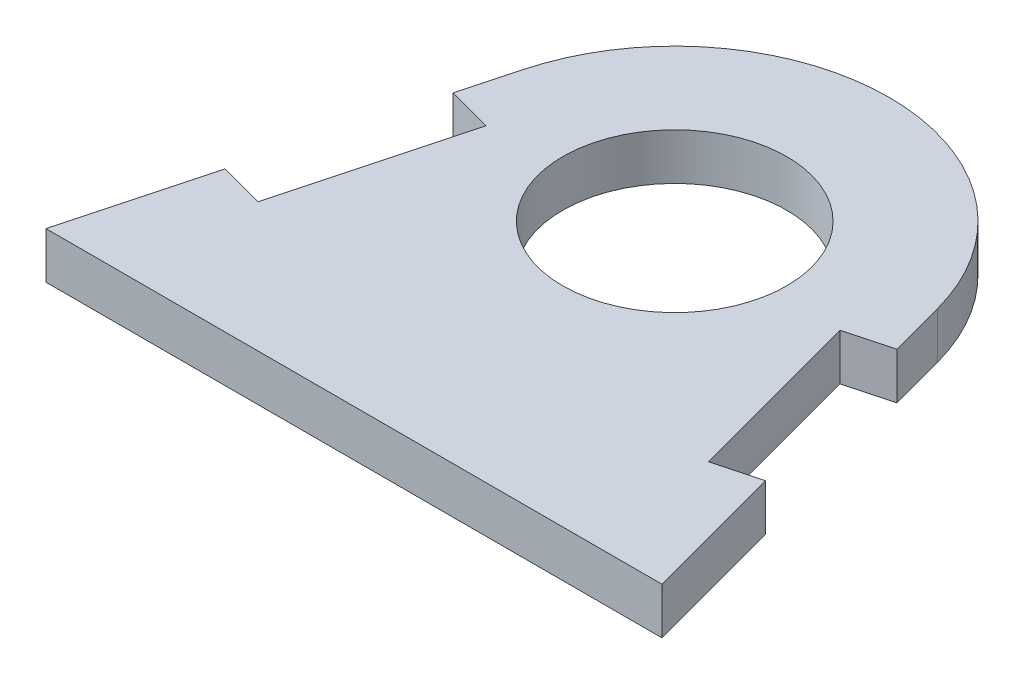
from build123d import *

# Parameters (mm, degrees)
SKETCH1_R           = 7.65
BOSS_EXTRUDE1_DEPTH = 1.5875


with BuildPart() as part:
    # Sketch1 → Boss-Extrude1 (new, symmetric)
    with BuildSketch(Plane(origin=(0, 0, 0), x_dir=(1, 0, 0), z_dir=(0, 1, 0))):
        with BuildLine():
            Line((-18.450042271, 9.659258263), (-21.038232722, 0))
            Line((-21.038232722, 0), (21.038232722, 0))
            Line((21.038232722, 0), (18.450042271, 9.659258263))
            Line((18.450042271, 9.659258263), (15.383227773, 8.837507795))
            Line((15.383227773, 8.837507795), (12.0962259, 21.104765789))
            Line((12.0962259, 21.104765789), (15.163040398, 21.926516257))
            Line((15.163040398, 21.926516257), (14.150813355, 25.704199011))
            ThreePointArc((14.150813355, 25.704199011), (0, 36.5625), (-14.150813355, 25.704199011))
            Line((-14.150813355, 25.704199011), (-15.163040398, 21.926516257))
            Line((-15.163040398, 21.926516257), (-12.0962259, 21.104765789))
            Line((-12.0962259, 21.104765789), (-15.383227773, 8.837507795))
            Line((-15.383227773, 8.837507795), (-18.450042271, 9.659258263))
        make_face()
        with Locations((0, 21.9125)):
            Circle(SKETCH1_R, mode=Mode.SUBTRACT)
    extrude(amount=BOSS_EXTRUDE1_DEPTH, both=True)


solid = part.part
